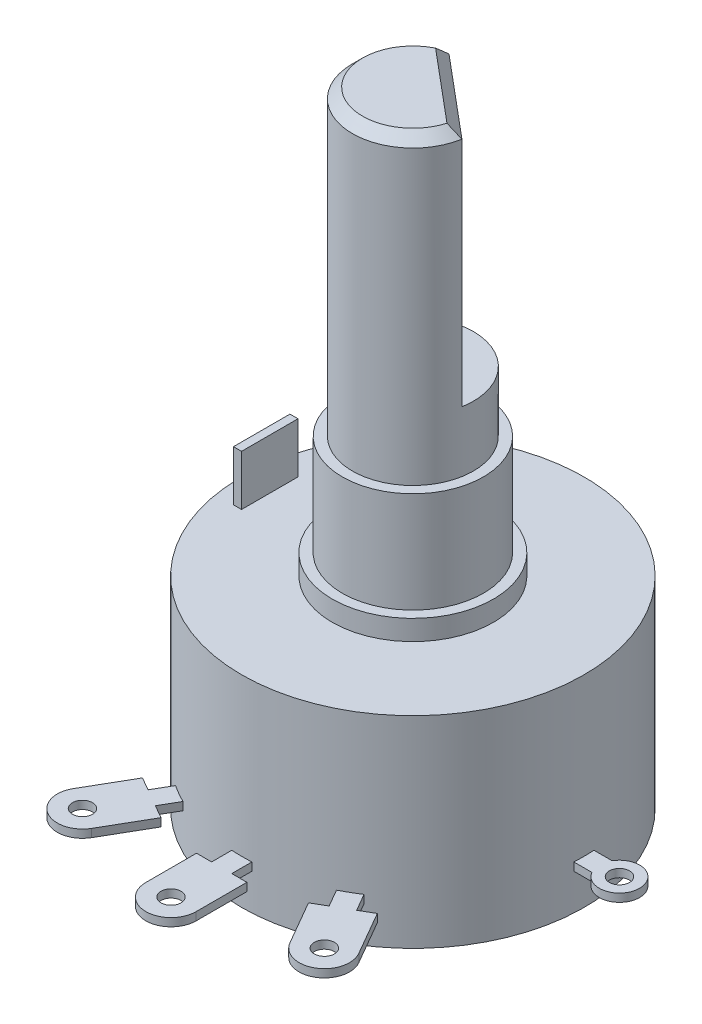
from build123d import *

# Parameters (mm, degrees)
SKETCH2_W           = 0.4
SKETCH2_H           = 2.8
BOSS_EXTRUDE1_DEPTH = 2.5
SKETCH3_R           = 0.5
BOSS_EXTRUDE2_DEPTH = 0.2
SKETCH4_R           = 3
BOSS_EXTRUDE4_DEPTH = 15
CUT_EXTRUDE1_DEPTH  = 12
CHAMFER1_SIZE       = 0.5


with BuildPart() as part:
    # Sketch1 → Revolve1 (revolve)
    with BuildSketch(Plane(origin=(0, 0, 0), x_dir=(0, 0, -1), z_dir=(1, 0, 0))):
        Polygon((0, 0), (8.5, 0), (8.5, 10), (4, 10), (4, 11), (3.5, 11), (3.5, 16), (0, 16), align=None)
    revolve(axis=Axis((0, 16, 0), (0, -1, 0)))

    # Sketch2 → Boss-Extrude1 (add)
    with BuildSketch(Plane(origin=(0, 10, 0), x_dir=(1, 0, 0), z_dir=(0, 1, 0))):
        with Locations((-7.3, 0)):
            Rectangle(SKETCH2_W, SKETCH2_H)
    extrude(amount=BOSS_EXTRUDE1_DEPTH)

    # Sketch3 → Boss-Extrude2 (add, symmetric)
    with BuildSketch(Plane(origin=(0, 2, 0), x_dir=(-1, 0, 0), z_dir=(0, -1, 0))):
        with BuildLine():
            Line((-1.25, -9.485281374), (-1.25, -12))
            ThreePointArc((-1.25, -12), (0, -13.25), (1.25, -12))
            Line((1.25, -12), (1.25, -9.485281374))
            Line((1.25, -9.485281374), (0.5, -9.485281374))
            Line((0.5, -9.485281374), (0.5, -8.485281374))
            ThreePointArc((0.5, -8.485281374), (0, -8.5), (-0.5, -8.485281374))
            Line((-0.5, -8.485281374), (-0.5, -9.485281374))
            Line((-0.5, -9.485281374), (-1.25, -9.485281374))
        make_face()
        with Locations((0, -12)):
            Circle(SKETCH3_R, mode=Mode.SUBTRACT)
        with BuildLine():
            Line((-5.825172442, -7.589494632), (-7.082531755, -9.767304845))
            ThreePointArc((-7.082531755, -9.767304845), (-6.625, -11.4748366), (-4.917468245, -11.017304845))
            Line((-4.917468245, -11.017304845), (-3.660108932, -8.839494632))
            Line((-3.660108932, -8.839494632), (-4.309627985, -8.464494632))
            Line((-4.309627985, -8.464494632), (-3.809627985, -7.598469228))
            ThreePointArc((-3.809627985, -7.598469228), (-4.25, -7.361215932), (-4.675653389, -7.098469228))
            Line((-4.675653389, -7.098469228), (-5.175653389, -7.964494632))
            Line((-5.175653389, -7.964494632), (-5.825172442, -7.589494632))
        make_face()
        with Locations((-6, -10.392304845)):
            Circle(SKETCH3_R, mode=Mode.SUBTRACT)
        with BuildLine():
            Line((5.175653389, -7.964494632), (4.675653389, -7.098469228))
            ThreePointArc((4.675653389, -7.098469228), (4.25, -7.361215932), (3.809627985, -7.598469228))
            Line((3.809627985, -7.598469228), (4.309627985, -8.464494632))
            Line((4.309627985, -8.464494632), (3.660108932, -8.839494632))
            Line((3.660108932, -8.839494632), (4.917468245, -11.017304845))
            ThreePointArc((4.917468245, -11.017304845), (6.625, -11.4748366), (7.082531755, -9.767304845))
            Line((7.082531755, -9.767304845), (5.825172442, -7.589494632))
            Line((5.825172442, -7.589494632), (5.175653389, -7.964494632))
        make_face()
        with Locations((6, -10.392304845)):
            Circle(SKETCH3_R, mode=Mode.SUBTRACT)
        with BuildLine():
            Line((9.383974596, 0.5), (8.485281374, 0.5))
            ThreePointArc((8.485281374, 0.5), (8.5, 0), (8.485281374, -0.5))
            Line((8.485281374, -0.5), (9.383974596, -0.5))
            ThreePointArc((9.383974596, -0.5), (11.25, 0), (9.383974596, 0.5))
        make_face()
        with Locations((10.25, 0)):
            Circle(SKETCH3_R, mode=Mode.SUBTRACT)
        with BuildLine():
            Line((-9.383974596, -0.5), (-8.485281374, -0.5))
            ThreePointArc((-8.485281374, -0.5), (-8.5, 0), (-8.485281374, 0.5))
            Line((-8.485281374, 0.5), (-9.383974596, 0.5))
            ThreePointArc((-9.383974596, 0.5), (-11.25, 0), (-9.383974596, -0.5))
        make_face()
        with Locations((-10.25, 0)):
            Circle(SKETCH3_R, mode=Mode.SUBTRACT)
    extrude(amount=BOSS_EXTRUDE2_DEPTH, both=True)

    # Sketch4 → Boss-Extrude4 (add)
    with BuildSketch(Plane(origin=(0, 16, 0), x_dir=(1, 0, 0), z_dir=(0, 1, 0))):
        Circle(SKETCH4_R)
    extrude(amount=BOSS_EXTRUDE4_DEPTH)

    # Sketch5 → Cut-Extrude1 (cut)
    with BuildSketch(Plane(origin=(0, 31, 0), x_dir=(1, 0, 0), z_dir=(0, 1, 0))):
        with BuildLine():
            Line((2.954423259, -0.520944533), (-1.02606043, 2.819077862))
            ThreePointArc((-1.02606043, 2.819077862), (1.928362829, 2.298133329), (2.954423259, -0.520944533))
        make_face()
    extrude(amount=-CUT_EXTRUDE1_DEPTH, mode=Mode.SUBTRACT)

    # Chamfer1
    chamfer1_edges = [part.edges().sort_by_distance(p)[0] for p in [
        (-1.928362829, 31, 2.298133329),
        (0.964181415, 31, -1.149066665),
    ]]
    chamfer(chamfer1_edges, length=CHAMFER1_SIZE)


solid = part.part
